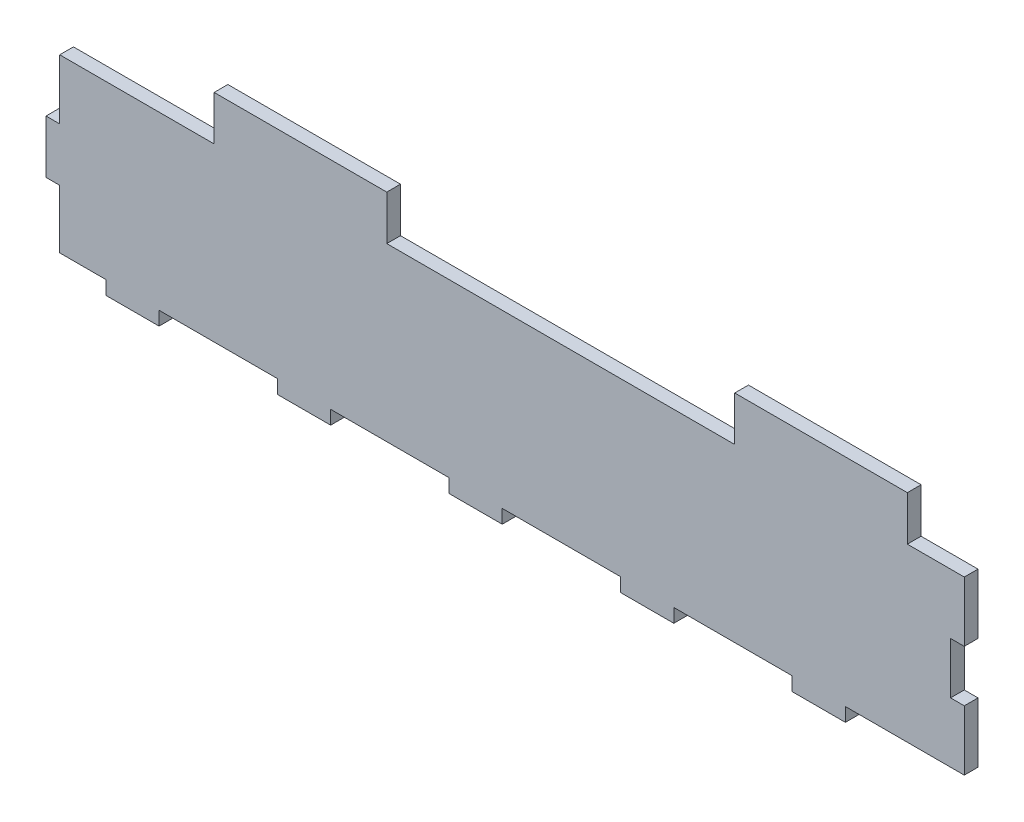
from build123d import *

# Parameters (mm, degrees)
SKIZZE1_W                       = 300
SKIZZE1_H                       = 50
AUFSATZ_LINEAR_AUSTRAGEN1_DEPTH = 4
SKIZZE2_W                       = 15.5
SKIZZE2_H                       = 4
AUFSATZ_LINEAR_AUSTRAGEN3_DEPTH = 4
SCHNITT_LINEAR_AUSTRAGEN1_REACH = 6
SKIZZE3_W                       = 4
SKIZZE3_H                       = 17.45
SKIZZE3_H_2                     = 17.05
SKIZZE4_W                       = 50.3
SKIZZE4_H                       = 13
AUFSATZ_LINEAR_AUSTRAGEN4_DEPTH = 4
SCHNITT_LINEAR_AUSTRAGEN2_REACH = 6


with BuildPart() as part:
    # Skizze1 → Aufsatz-Linear austragen1 (new body)
    with BuildSketch(Plane.XY):
        with Locations((150, 25)):
            Rectangle(SKIZZE1_W, SKIZZE1_H)
    extrude(amount=AUFSATZ_LINEAR_AUSTRAGEN1_DEPTH)

    # Skizze2 → Aufsatz-Linear austragen3 (add)
    with BuildSketch(Plane.XY):
        with Locations((25.2, -2)):
            Rectangle(SKIZZE2_W, SKIZZE2_H)
        with Locations((75.2, -2)):
            Rectangle(SKIZZE2_W, SKIZZE2_H)
        with Locations((125.2, -2)):
            Rectangle(SKIZZE2_W, SKIZZE2_H)
        with Locations((175.2, -2)):
            Rectangle(SKIZZE2_W, SKIZZE2_H)
        with Locations((225.2, -2)):
            Rectangle(SKIZZE2_W, SKIZZE2_H)
        with Locations((275.2, -2)):
            Rectangle(SKIZZE2_W, SKIZZE2_H)
    extrude(amount=AUFSATZ_LINEAR_AUSTRAGEN3_DEPTH)

    # Skizze3 → Schnitt-Linear austragen1 (cut, up to next)
    with BuildSketch(Plane.XY.offset(4), mode=Mode.PRIVATE) as schnitt_linear_austragen1_sk1:
        with Locations((2, 41.275)):
            Rectangle(SKIZZE3_W, SKIZZE3_H)
    schnitt_linear_austragen1_tool1 = extrude(schnitt_linear_austragen1_sk1.sketch, amount=-SCHNITT_LINEAR_AUSTRAGEN1_REACH, mode=Mode.PRIVATE) & part.part
    add(schnitt_linear_austragen1_tool1.solids().sort_by_distance((2, 41.275, 4))[0], mode=Mode.SUBTRACT)
    # Skizze3 → Schnitt-Linear austragen1 (cut, up to next)
    with BuildSketch(Plane.XY.offset(4), mode=Mode.PRIVATE) as schnitt_linear_austragen1_sk2:
        with Locations((2, 8.525)):
            Rectangle(SKIZZE3_W, SKIZZE3_H_2)
    schnitt_linear_austragen1_tool2 = extrude(schnitt_linear_austragen1_sk2.sketch, amount=-SCHNITT_LINEAR_AUSTRAGEN1_REACH, mode=Mode.PRIVATE) & part.part
    add(schnitt_linear_austragen1_tool2.solids().sort_by_distance((2, 8.525, 4))[0], mode=Mode.SUBTRACT)
    # Skizze3 → Schnitt-Linear austragen1 (cut, up to next)
    with BuildSketch(Plane.XY.offset(4), mode=Mode.PRIVATE) as schnitt_linear_austragen1_sk3:
        with Locations((298, 8.525)):
            Rectangle(SKIZZE3_W, SKIZZE3_H_2)
    schnitt_linear_austragen1_tool3 = extrude(schnitt_linear_austragen1_sk3.sketch, amount=-SCHNITT_LINEAR_AUSTRAGEN1_REACH, mode=Mode.PRIVATE) & part.part
    add(schnitt_linear_austragen1_tool3.solids().sort_by_distance((298, 8.525, 4))[0], mode=Mode.SUBTRACT)
    # Skizze3 → Schnitt-Linear austragen1 (cut, up to next)
    with BuildSketch(Plane.XY.offset(4), mode=Mode.PRIVATE) as schnitt_linear_austragen1_sk4:
        with Locations((298, 41.275)):
            Rectangle(SKIZZE3_W, SKIZZE3_H)
    schnitt_linear_austragen1_tool4 = extrude(schnitt_linear_austragen1_sk4.sketch, amount=-SCHNITT_LINEAR_AUSTRAGEN1_REACH, mode=Mode.PRIVATE) & part.part
    add(schnitt_linear_austragen1_tool4.solids().sort_by_distance((298, 41.275, 4))[0], mode=Mode.SUBTRACT)

    # Skizze4 → Aufsatz-Linear austragen4 (add)
    with BuildSketch(Plane.XY.offset(4)):
        with Locations((74.15, 56.5)):
            Rectangle(SKIZZE4_W, SKIZZE4_H)
        with Locations((225.85, 56.5)):
            Rectangle(SKIZZE4_W, SKIZZE4_H)
    extrude(amount=-AUFSATZ_LINEAR_AUSTRAGEN4_DEPTH)

    # Skizze5 → Schnitt-Linear austragen2 (cut, up to next)
    with BuildSketch(Plane(origin=(0, 0, 0), x_dir=(-1, 0, 0), z_dir=(0, 0, -1)), mode=Mode.PRIVATE) as schnitt_linear_austragen2_sk1:
        Polygon((-267.589208013, 50), (-267.589208013, 32.5), (-263.589208013, 32.5), (-263.589208013, 17.5), (-267.589208013, 17.5), (-267.589208013, 0), (-260.181086132, 0), (-260.181086132, -8.903305995), (-305.118419692, -8.903305995), (-305.118419692, 50), align=None)
    schnitt_linear_austragen2_tool1 = extrude(schnitt_linear_austragen2_sk1.sketch, amount=-SCHNITT_LINEAR_AUSTRAGEN2_REACH, mode=Mode.PRIVATE) & part.part
    add(schnitt_linear_austragen2_tool1.solids().sort_by_distance((285.186351, 19.956954, 0))[0], mode=Mode.SUBTRACT)


solid = part.part
